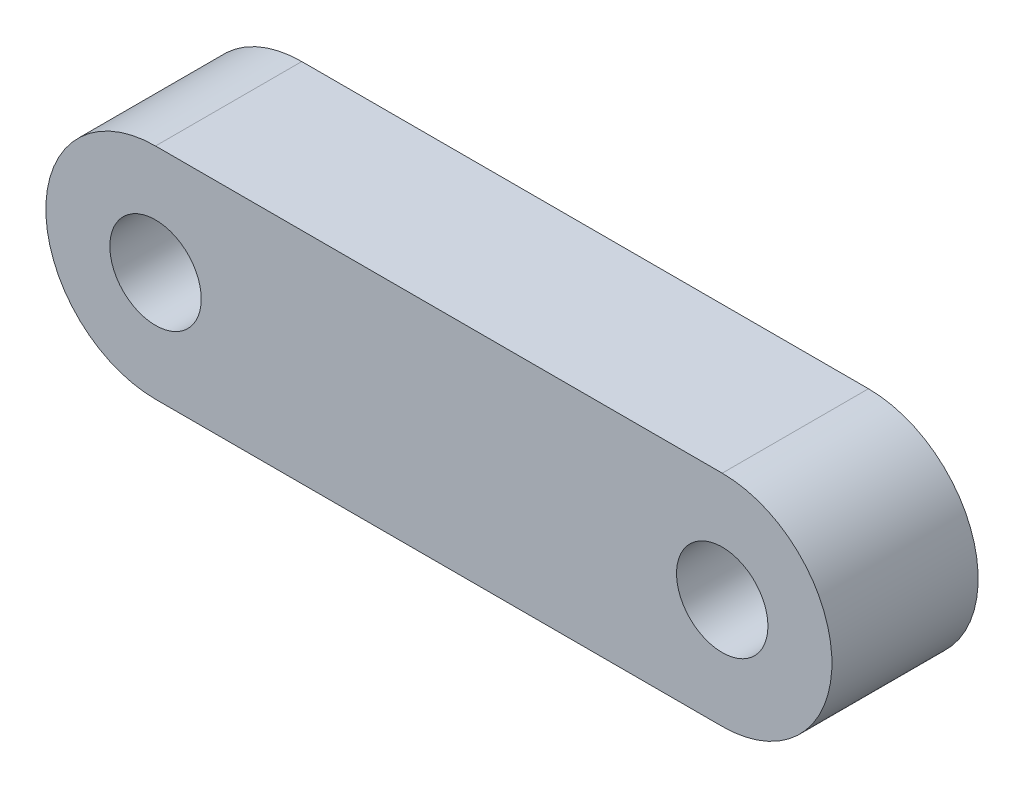
from build123d import *

# Parameters (mm, degrees)
RESSALTO_EXTRUS_O1_DEPTH  = 4
FURO_ROSCADO_DE_M3X0_51_D = 2.5


with BuildPart() as part:
    # Esboço1 → Ressalto-extrusão1 (new body)
    with BuildSketch(Plane.XY):
        with BuildLine():
            Line((-7.75, 3), (7.75, 3))
            ThreePointArc((7.75, 3), (10.75, 0), (7.75, -3))
            Line((7.75, -3), (-7.75, -3))
            ThreePointArc((-7.75, -3), (-10.75, 0), (-7.75, 3))
        make_face()
    extrude(amount=RESSALTO_EXTRUS_O1_DEPTH)

    # Furo roscado de M3x0.51 (through all)
    with Locations(Plane.XY.offset(4)):
        with Locations((7.75, 0), (-7.75, 0)):
            Hole(FURO_ROSCADO_DE_M3X0_51_D / 2)


solid = part.part
